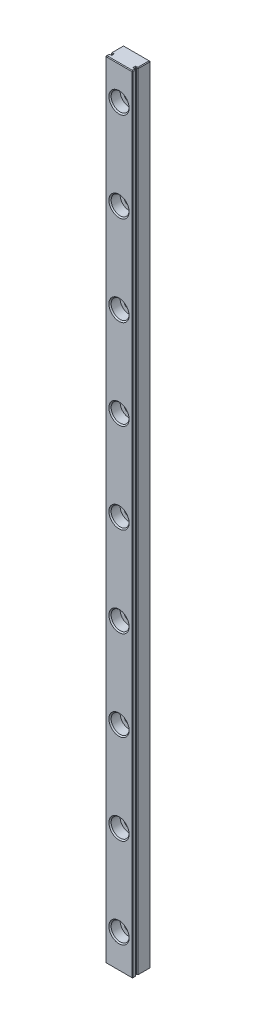
from build123d import *

# Parameters (mm, degrees)
SKETCH_1_W                         = 12
SKETCH_1_H                         = 8
EXTRUDE_1_DEPTH                    = 350
CUT_EXTRUDE_1_DEPTH                = 351
CHAMFER_1_SIZE                     = 0.5
PATTERN_LINEAR_1_COUNT             = 9
PATTERN_LINEAR_1_PITCH             = 40
CHAMFER_1_OF_PATTERN_LINEAR_1_SIZE = 0.5
CHAMFER_2_SIZE                     = 0.3


with BuildPart() as part:
    # Эскиз1 → Бобышка-Вытянуть1 (new body)
    with BuildSketch(Plane(origin=(0, 0, 0), x_dir=(1, 0, 0), z_dir=(0, 1, 0))):
        with Locations((6, 4)):
            Rectangle(SKETCH_1_W, SKETCH_1_H)
    extrude(amount=EXTRUDE_1_DEPTH)

    # Эскиз2 → Вырез-Вытянуть1 (cut, through all)
    with BuildSketch(Plane(origin=(0, 350, 0), x_dir=(1, 0, 0), z_dir=(0, 1, 0))):
        with BuildLine():
            Line((11, 2.25), (11, 1.75))
            Line((11, 1.75), (11.5, 1.75))
            ThreePointArc((11.5, 1.75), (11.706107374, 1.524471742), (12, 1.440983006))
            Line((12, 1.440983006), (12, 2.559016994))
            ThreePointArc((12, 2.559016994), (11.706107374, 2.475528258), (11.5, 2.25))
            Line((11.5, 2.25), (11, 2.25))
        make_face()
    cut_extrude_1 = extrude(amount=-CUT_EXTRUDE_1_DEPTH, mode=Mode.SUBTRACT)

    # Зеркальное отражение1: Вырез-Вытянуть1 across plane
    add(cut_extrude_1.mirror(Plane(origin=(6, 0, 0), x_dir=(0, 0, 1), z_dir=(1, 0, 0))), mode=Mode.SUBTRACT)

    # Эскиз4 → Вырез-Повернуть1 (revolve, cut)
    with BuildSketch(Plane(origin=(6, 0, 0), x_dir=(0, 0, -1), z_dir=(1, 0, 0))):
        Polygon((0, 339), (4.5, 339), (4.5, 337.25), (8, 337.25), (8, 335), (0, 335), align=None)
    cut_revolve_1 = revolve(axis=Axis((6, 335, -8), (0, 0, 1)), mode=Mode.SUBTRACT)

    # Фаска1
    chamfer_1_edges = [part.edges().sort_by_distance(p)[0] for p in [
        (6, 331, 0),
        (6, 332.75, -8),
    ]]
    chamfer(chamfer_1_edges, length=CHAMFER_1_SIZE)

    # Линейный массив1: Вырез-Повернуть1 ×9
    with Locations(*[(0, -i * PATTERN_LINEAR_1_PITCH, 0) for i in range(1, PATTERN_LINEAR_1_COUNT)]):
        add(cut_revolve_1, mode=Mode.SUBTRACT)

    # Фаска1 of Линейный массив1
    chamfer_1_of_pattern_linear_1_edges = [part.edges().sort_by_distance(p)[0] for p in [
        (6, 291, 0),
        (6, 292.75, -8),
        (6, 251, 0),
        (6, 252.75, -8),
        (6, 211, 0),
        (6, 212.75, -8),
        (6, 171, 0),
        (6, 172.75, -8),
        (6, 131, 0),
        (6, 132.75, -8),
        (6, 91, 0),
        (6, 92.75, -8),
        (6, 51, 0),
        (6, 52.75, -8),
        (6, 11, 0),
        (6, 12.75, -8),
    ]]
    chamfer(chamfer_1_of_pattern_linear_1_edges, length=CHAMFER_1_OF_PATTERN_LINEAR_1_SIZE)

    # Фаска2
    chamfer_2_edges = [part.edges().sort_by_distance(p)[0] for p in [
        (12, 350, -0.720491503),
        (6, 350, -8),
        (12, 0, -5.279508497),
        (12, 350, -5.279508497),
        (11.25, 0, -2.25),
        (11.706107374, 0, -2.475528258),
        (11.706107374, 0, -1.524471742),
        (11.25, 0, -1.75),
        (11, 0, -2),
        (11.25, 350, -2.25),
        (11, 350, -2),
        (11.25, 350, -1.75),
        (11.706107374, 350, -1.524471742),
        (11.706107374, 350, -2.475528258),
        (0, 0, -0.720491503),
        (0, 350, -0.720491503),
        (0, 350, -5.279508497),
        (0.75, 350, -2.25),
        (1, 350, -2),
        (0.75, 350, -1.75),
        (0.293892626, 350, -1.524471742),
        (0.293892626, 350, -2.475528258),
        (0.75, 0, -2.25),
        (6, 0, -8),
        (1, 0, -2),
        (0.75, 0, -1.75),
        (0.293892626, 0, -1.524471742),
        (0.293892626, 0, -2.475528258),
        (12, 0, -0.720491503),
        (6, 0, 0),
        (0, 0, -5.279508497),
        (6, 350, 0),
        (0, 175, -8),
        (12, 175, -8),
        (12, 175, 0),
        (0, 175, 0),
    ]]
    chamfer(chamfer_2_edges, length=CHAMFER_2_SIZE)


solid = part.part
